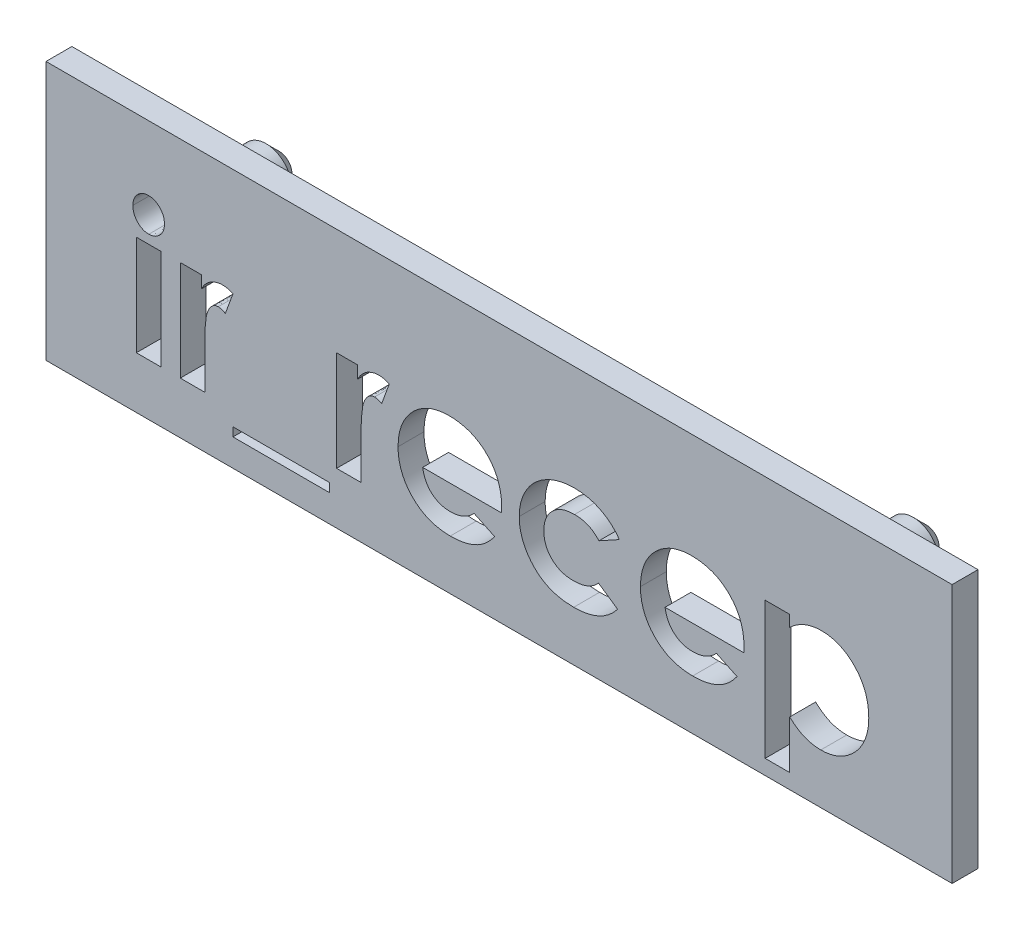
from build123d import *

# Parameters (mm, degrees)
ESQUISSE1_W             = 35
ESQUISSE1_H             = 10
BOSS_EXTRU_1_DEPTH      = 1
ESQUISSE2_R             = 1
BOSS_EXTRU_2_DEPTH      = 3
CHANFREIN1_SIZE         = 0.5
ESQUISSE3_W             = 0.949786325
ESQUISSE3_H             = 3.866987179
ESQUISSE3_W_2           = 3.731303419
ESQUISSE3_H_2           = 0.339209402
ENL_V_MAT_EXTRU_2_DEPTH = 1


with BuildPart() as part:
    # Esquisse1 → Boss.-Extru.1 (new body)
    with BuildSketch(Plane.XY):
        with Locations((17.5, -5)):
            Rectangle(ESQUISSE1_W, ESQUISSE1_H)
    extrude(amount=BOSS_EXTRU_1_DEPTH)

    # Esquisse2 → Boss.-Extru.2 (add)
    with BuildSketch(Plane(origin=(0, 0, 0), x_dir=(-1, 0, 0), z_dir=(0, 0, -1))):
        with Locations(Location((-30, -3, 0), (0, 0, 180))):  # turned: the seam where the file's is
            Circle(ESQUISSE2_R)
        with Locations(Location((-5, -3, 0), (0, 0, 180))):  # turned: the seam where the file's is
            Circle(ESQUISSE2_R)
    extrude(amount=BOSS_EXTRU_2_DEPTH)

    # Chanfrein1
    chanfrein1_edges = [part.edges().sort_by_distance(p)[0] for p in [
        (29, -3, -3),
        (4, -3, -3),
    ]]
    chamfer(chanfrein1_edges, length=CHANFREIN1_SIZE)

    # Esquisse3 → Enlèv. mat.-Extru.2 (cut)
    with BuildSketch(Plane.XY.offset(1)):
        with BuildLine():
            add(Edge.make_bspline(
                [(3.963424813, -2.504807692), (4.004360597, -2.506816157), (4.084741953, -2.51075997), (4.199899183, -2.549203379), (4.305590182, -2.609539161), (4.399023956, -2.692321292), (4.476733433, -2.791178297), (4.536106359, -2.901855287), (4.569180543, -3.024481827), (4.573774058, -3.109190958), (4.576121795, -3.152485644)],
                knots=[0, 0, 0, 0, 0.989868614, 1.943702388, 2.910836514, 3.924849579, 4.949916355, 5.946401046, 6.950409252, 8, 8, 8, 8], degree=3))
            add(Edge.make_bspline(
                [(4.576121795, -3.152485644), (4.573858056, -3.195461271), (4.569447052, -3.279201328), (4.535345136, -3.400163155), (4.478355233, -3.510786389), (4.400016358, -3.608175184), (4.307595528, -3.68962406), (4.204213959, -3.751055201), (4.090160268, -3.787360012), (4.011026189, -3.791633507), (3.970845019, -3.793803419)],
                knots=[0, 0, 0, 0, 1.05296456, 2.051751585, 3.055639087, 4.085634717, 5.099016424, 6.062201612, 7.016062274, 8, 8, 8, 8], degree=3))
            add(Edge.make_bspline(
                [(3.970845019, -3.793803419), (3.929551899, -3.791802134), (3.848471229, -3.787872533), (3.732369472, -3.749339175), (3.625268825, -3.689478577), (3.532240366, -3.605005079), (3.453640943, -3.50544562), (3.396861449, -3.392191974), (3.361344472, -3.268726916), (3.357128638, -3.182763185), (3.354967949, -3.138705262)],
                knots=[0, 0, 0, 0, 0.989065327, 1.942068821, 2.907541208, 3.917690034, 4.939857478, 5.938239964, 6.943311734, 8, 8, 8, 8], degree=3))
            add(Edge.make_bspline(
                [(3.354967949, -3.138705262), (3.357319369, -3.096459386), (3.361938395, -3.013473462), (3.395210697, -2.893573269), (3.453222204, -2.784756933), (3.530371931, -2.687709598), (3.622985043, -2.606471665), (3.728612594, -2.547968321), (3.842994812, -2.511112734), (3.92286698, -2.506931074), (3.963424813, -2.504807692)],
                knots=[0, 0, 0, 0, 1.038616768, 2.040212704, 3.031499824, 4.052181184, 5.074969369, 6.039807101, 7.004644834, 8, 8, 8, 8], degree=3))
        make_face()
        with Locations((3.965544872, -6.066506411)):
            Rectangle(ESQUISSE3_W, ESQUISSE3_H)
        with BuildLine():
            Line((5.186698718, -4.133012821), (6.000801282, -4.133012821))
            Line((6.000801282, -4.133012821), (6.000801282, -4.608966012))
            add(Edge.make_bspline(
                [(6.000801282, -4.608966012), (6.023830681, -4.566667921), (6.068842596, -4.483994547), (6.151533259, -4.373021915), (6.246531642, -4.27956386), (6.350424159, -4.201665623), (6.463525688, -4.140951595), (6.582807572, -4.097685197), (6.707249356, -4.069568033), (6.792139323, -4.066647192), (6.835044404, -4.06517094)],
                knots=[0, 0, 0, 0, 1.09866127, 2.147379032, 3.14564304, 4.131443017, 5.102343063, 6.064490016, 7.021754664, 8, 8, 8, 8], degree=3))
            add(Edge.make_bspline(
                [(6.835044404, -4.06517094), (6.866198847, -4.066629785), (6.929640418, -4.069600514), (7.026334298, -4.086869409), (7.124423302, -4.118094854), (7.188974319, -4.146209218), (7.221955128, -4.160573584)],
                knots=[0, 0, 0, 0, 0.931404136, 1.896671404, 2.925354185, 4, 4, 4, 4], degree=3))
            Line((7.221955128, -4.160573584), (6.92726696, -4.965135884))
            add(Edge.make_bspline(
                [(6.92726696, -4.965135884), (6.900926046, -4.952409228), (6.851415268, -4.928488014), (6.779534215, -4.900258516), (6.714299178, -4.883034257), (6.672941362, -4.880464246), (6.65377938, -4.879273504)],
                knots=[0, 0, 0, 0, 1.214386998, 2.282580073, 3.20428172, 4, 4, 4, 4], degree=3))
            add(Edge.make_bspline(
                [(6.65377938, -4.879273504), (6.635686743, -4.880062553), (6.600095407, -4.881614748), (6.547563592, -4.894916529), (6.498089562, -4.917855038), (6.449289164, -4.947241545), (6.405012211, -4.988090988), (6.360762607, -5.03538147), (6.321767486, -5.093767862), (6.280616325, -5.15875488), (6.245577582, -5.238298932), (6.215532939, -5.333258138), (6.188762921, -5.444731242), (6.170341494, -5.57331011), (6.152536445, -5.717750521), (6.141938443, -5.879112649), (6.134039617, -6.056886251), (6.133556657, -6.180978642), (6.133304955, -6.245651376)],
                knots=[0, 0, 0, 0, 0.544232178, 1.070598461, 1.618251235, 2.182094276, 2.777567932, 3.425210017, 4.127676488, 4.886675562, 5.738955394, 6.734782583, 7.883056018, 9.186093582, 10.642914445, 12.264202625, 14.053029461, 16, 16, 16, 16], degree=3))
            Line((6.133304955, -6.245651376), (6.136485043, -6.434336605))
            Line((6.136485043, -6.434336605), (6.136485043, -8))
            Line((6.136485043, -8), (5.186698718, -8))
            Line((5.186698718, -8), (5.186698718, -4.133012821))
        make_face()
        with Locations((9.087606838, -8.780181624)):
            Rectangle(ESQUISSE3_W_2, ESQUISSE3_H_2)
        with BuildLine():
            Line((11.224626068, -4.133012821), (12.038728632, -4.133012821))
            Line((12.038728632, -4.133012821), (12.038728632, -4.608966012))
            add(Edge.make_bspline(
                [(12.038728632, -4.608966012), (12.061758031, -4.566667921), (12.106769946, -4.483994547), (12.189460609, -4.373021915), (12.284458992, -4.27956386), (12.38835151, -4.201665623), (12.501453039, -4.140951595), (12.620734923, -4.097685197), (12.745176707, -4.069568033), (12.830066673, -4.066647192), (12.872971755, -4.06517094)],
                knots=[0, 0, 0, 0, 1.09866127, 2.147379032, 3.14564304, 4.131443017, 5.102343063, 6.064490016, 7.021754664, 8, 8, 8, 8], degree=3))
            add(Edge.make_bspline(
                [(12.872971755, -4.06517094), (12.904126198, -4.066629785), (12.967567768, -4.069600514), (13.064261649, -4.086869409), (13.162350652, -4.118094854), (13.226901669, -4.146209218), (13.259882479, -4.160573584)],
                knots=[0, 0, 0, 0, 0.931404136, 1.896671404, 2.925354185, 4, 4, 4, 4], degree=3))
            Line((13.259882479, -4.160573584), (12.965194311, -4.965135884))
            add(Edge.make_bspline(
                [(12.965194311, -4.965135884), (12.938853397, -4.952409228), (12.889342618, -4.928488014), (12.817461565, -4.900258516), (12.752226529, -4.883034257), (12.710868713, -4.880464246), (12.691706731, -4.879273504)],
                knots=[0, 0, 0, 0, 1.214386998, 2.282580073, 3.20428172, 4, 4, 4, 4], degree=3))
            add(Edge.make_bspline(
                [(12.691706731, -4.879273504), (12.673614093, -4.880062553), (12.638022758, -4.881614748), (12.585490943, -4.894916529), (12.536016912, -4.917855038), (12.487216515, -4.947241545), (12.442939562, -4.988090988), (12.398689957, -5.03538147), (12.359694836, -5.093767862), (12.318543675, -5.15875488), (12.283504933, -5.238298932), (12.25346029, -5.333258138), (12.226690272, -5.444731242), (12.208268844, -5.57331011), (12.190463795, -5.717750521), (12.179865793, -5.879112649), (12.171966968, -6.056886251), (12.171484007, -6.180978642), (12.171232305, -6.245651376)],
                knots=[0, 0, 0, 0, 0.544232178, 1.070598461, 1.618251235, 2.182094276, 2.777567932, 3.425210017, 4.127676488, 4.886675562, 5.738955394, 6.734782583, 7.883056018, 9.186093582, 10.642914445, 12.264202625, 14.053029461, 16, 16, 16, 16], degree=3))
            Line((12.171232305, -6.245651376), (12.174412393, -6.434336605))
            Line((12.174412393, -6.434336605), (12.174412393, -8))
            Line((12.174412393, -8), (11.224626068, -8))
            Line((11.224626068, -8), (11.224626068, -4.133012821))
        make_face()
        with BuildLine():
            Line((17.598582732, -6.303952991), (14.548878205, -6.303952991))
            add(Edge.make_bspline(
                [(14.548878205, -6.303952991), (14.555096306, -6.339388828), (14.567315366, -6.409023042), (14.593849488, -6.510172781), (14.627711008, -6.605494587), (14.668291907, -6.695115884), (14.714907991, -6.779510462), (14.769281791, -6.858282479), (14.830723625, -6.931362358), (14.898878253, -6.998432487), (14.97260966, -7.058528775), (15.051560278, -7.111176923), (15.135811576, -7.154345184), (15.224397647, -7.190731548), (15.317980432, -7.219553234), (15.416697662, -7.239431004), (15.520287651, -7.251172875), (15.590856316, -7.252871202), (15.626928085, -7.253739316)],
                knots=[0, 0, 0, 0, 1.091296461, 2.144483647, 3.168565212, 4.157007626, 5.126487748, 6.090021542, 7.05641414, 8.019231907, 8.98705074, 9.938580405, 10.892824166, 11.854447369, 12.841318655, 13.858982407, 14.905600794, 16, 16, 16, 16], degree=3))
            add(Edge.make_bspline(
                [(15.626928085, -7.253739316), (15.670469158, -7.25258979), (15.756214355, -7.250326034), (15.881831706, -7.23024988), (16.003321983, -7.199925733), (16.119535459, -7.15483118), (16.231818286, -7.098696389), (16.338321943, -7.028759346), (16.440889925, -6.947063841), (16.503468481, -6.884092976), (16.535373264, -6.851988181)],
                knots=[0, 0, 0, 0, 1.021034703, 2.010718019, 2.977989445, 3.954245119, 4.929443971, 5.918328161, 6.938689359, 8, 8, 8, 8], degree=3))
            Line((16.535373264, -6.851988181), (17.330395299, -7.23041867))
            add(Edge.make_bspline(
                [(17.330395299, -7.23041867), (17.305364494, -7.2650074), (17.255766875, -7.333543698), (17.174800426, -7.42999197), (17.090306781, -7.51998212), (17.002222925, -7.602922269), (16.910437145, -7.678576072), (16.815204767, -7.747865128), (16.715134009, -7.808929053), (16.612225767, -7.864722083), (16.504352738, -7.91255319), (16.391813455, -7.953341869), (16.275084583, -7.990214488), (16.15269209, -8.018309404), (16.025655137, -8.04054911), (15.893669827, -8.056342248), (15.756753554, -8.066096912), (15.663692362, -8.067253315), (15.616327791, -8.06784188)],
                knots=[0, 0, 0, 0, 1.028154879, 2.037251081, 3.030720504, 4.000128189, 4.949298328, 5.894184978, 6.834267904, 7.770992897, 8.712077017, 9.673380525, 10.653304757, 11.658697181, 12.695551717, 13.758623199, 14.859225354, 16, 16, 16, 16], degree=3))
            add(Edge.make_bspline(
                [(15.616327791, -8.06784188), (15.543458177, -8.066356288), (15.400747238, -8.063446841), (15.192006692, -8.036443012), (14.993761069, -7.991667753), (14.805450594, -7.930802664), (14.627889269, -7.85044168), (14.460989219, -7.752153529), (14.303082873, -7.637822594), (14.158995153, -7.505049371), (14.027726989, -7.360533612), (13.912429196, -7.205333555), (13.815949644, -7.040533524), (13.736718695, -6.867224201), (13.67513765, -6.684961981), (13.630741288, -6.49366733), (13.603525786, -6.293431612), (13.600586377, -6.157048736), (13.59909188, -6.087706998)],
                knots=[0, 0, 0, 0, 1.103565453, 2.161269334, 3.182010356, 4.179077853, 5.15417608, 6.128274628, 7.109042802, 8.101804412, 9.090965879, 10.063106201, 11.02526161, 11.978650795, 12.945248442, 13.93468508, 14.949922959, 16, 16, 16, 16], degree=3))
            add(Edge.make_bspline(
                [(13.59909188, -6.087706998), (13.600601086, -6.016603197), (13.60357038, -5.876709662), (13.630506963, -5.67185041), (13.675260391, -5.476386975), (13.737021574, -5.290050184), (13.815050579, -5.112257255), (13.912757668, -4.944563662), (14.027669773, -4.786385588), (14.158465046, -4.638463007), (14.303163167, -4.504946716), (14.45691859, -4.385957019), (14.621458917, -4.286806905), (14.794923053, -4.206693674), (14.976201461, -4.141603697), (15.167389465, -4.098291753), (15.367032415, -4.069210375), (15.50350394, -4.066532162), (15.572866587, -4.06517094)],
                knots=[0, 0, 0, 0, 1.079208495, 2.12329425, 3.130605359, 4.119693003, 5.099659317, 6.073216462, 7.060498243, 8.06384408, 9.066070512, 10.045757761, 11.010926815, 11.975797609, 12.942977511, 13.929384301, 14.947594487, 16, 16, 16, 16], degree=3))
            add(Edge.make_bspline(
                [(15.572866587, -4.06517094), (15.646085295, -4.06667958), (15.789842684, -4.06964164), (16.000037044, -4.096426204), (16.199598994, -4.141474498), (16.389378779, -4.201813297), (16.566952834, -4.284204284), (16.736222999, -4.380073719), (16.893129216, -4.496876004), (17.039343937, -4.628999478), (17.171332606, -4.775585892), (17.286705327, -4.934823635), (17.384873313, -5.105158639), (17.46443944, -5.287281648), (17.525957253, -5.480645912), (17.570394711, -5.68500031), (17.597402624, -5.901122106), (17.600287337, -6.049113087), (17.601762821, -6.124808026)],
                knots=[0, 0, 0, 0, 1.080001299, 2.120471247, 3.119684163, 4.095710327, 5.052285597, 6.002875087, 6.961153713, 7.931888285, 8.906493152, 9.865905668, 10.82813294, 11.801621613, 12.7925306, 13.817193356, 14.883530496, 16, 16, 16, 16], degree=3))
            Line((17.601762821, -6.124808026), (17.598582732, -6.303952991))
        make_face()
        with BuildLine():
            Line((22.147168803, -4.921674679), (21.360627003, -5.354166667))
            add(Edge.make_bspline(
                [(21.360627003, -5.354166667), (21.324574794, -5.318063555), (21.255273383, -5.248664299), (21.144143002, -5.16081585), (21.034998375, -5.088079778), (20.92333992, -5.034404293), (20.808169544, -4.993981508), (20.685333191, -4.96720861), (20.553397145, -4.949579608), (20.462136832, -4.947953728), (20.415080796, -4.947115385)],
                knots=[0, 0, 0, 0, 1.150764855, 2.212059359, 3.192108068, 4.105322427, 5.000809612, 5.941206042, 6.938435785, 8, 8, 8, 8], degree=3))
            add(Edge.make_bspline(
                [(20.415080796, -4.947115385), (20.371927163, -4.948157704), (20.287479123, -4.950197436), (20.164087135, -4.965432834), (20.046815695, -4.989361835), (19.935875311, -5.024370047), (19.831463579, -5.0706178), (19.73271706, -5.12534506), (19.640595309, -5.190689399), (19.556400493, -5.265721963), (19.480399873, -5.348331153), (19.412603443, -5.436437405), (19.357062156, -5.531347754), (19.309043269, -5.630831462), (19.273739197, -5.736757056), (19.247909879, -5.848163371), (19.233187409, -5.965055344), (19.231054383, -6.044912531), (19.229967949, -6.085586939)],
                knots=[0, 0, 0, 0, 1.121765476, 2.195200973, 3.227634963, 4.230038321, 5.213228299, 6.192116585, 7.160777141, 8.14345191, 9.118668839, 10.075979138, 11.027630062, 11.972829041, 12.943187208, 13.923755399, 14.94248691, 16, 16, 16, 16], degree=3))
            add(Edge.make_bspline(
                [(19.229967949, -6.085586939), (19.23111586, -6.125199879), (19.233357238, -6.202546952), (19.247127508, -6.316188233), (19.271033216, -6.424369883), (19.306876696, -6.526519978), (19.349839113, -6.623580196), (19.403792045, -6.714778598), (19.46723772, -6.800513425), (19.540510155, -6.880039516), (19.621677418, -6.951563477), (19.709182093, -7.01472654), (19.8027631, -7.068277132), (19.903510566, -7.110302311), (20.009781903, -7.144544041), (20.122286797, -7.168925493), (20.240905523, -7.182458885), (20.321764905, -7.184733534), (20.363139356, -7.185897436)],
                knots=[0, 0, 0, 0, 1.070556293, 2.090336998, 3.088792742, 4.058148387, 5.011235098, 5.952916408, 6.915475435, 7.888633318, 8.869583867, 9.83422472, 10.800707077, 11.776204622, 12.778807041, 13.814557445, 14.881744048, 16, 16, 16, 16], degree=3))
            add(Edge.make_bspline(
                [(20.363139356, -7.185897436), (20.414081222, -7.184731737), (20.513512341, -7.182456462), (20.658056332, -7.163158313), (20.79407025, -7.131245961), (20.921568518, -7.08707673), (21.040372765, -7.029324638), (21.150177731, -6.958784767), (21.252112208, -6.875977477), (21.31155478, -6.811419049), (21.341546474, -6.778846154)],
                knots=[0, 0, 0, 0, 1.116373375, 2.178998604, 3.189797796, 4.174590301, 5.13072713, 6.078291395, 7.030403691, 8, 8, 8, 8], degree=3))
            Line((21.341546474, -6.778846154), (22.079326923, -7.285540198))
            add(Edge.make_bspline(
                [(22.079326923, -7.285540198), (22.028187526, -7.348064577), (21.927267815, -7.471451686), (21.751190903, -7.630493165), (21.561678964, -7.767145135), (21.354920503, -7.876219005), (21.133926605, -7.962973325), (20.896970417, -8.024300017), (20.644452733, -8.060400427), (20.471028031, -8.065321747), (20.382219885, -8.06784188)],
                knots=[0, 0, 0, 0, 0.997876357, 1.969233105, 2.924898516, 3.881013542, 4.852507933, 5.855329832, 6.901747111, 8, 8, 8, 8], degree=3))
            add(Edge.make_bspline(
                [(20.382219885, -8.06784188), (20.302287046, -8.06599407), (20.146169399, -8.062385093), (19.918631806, -8.034747141), (19.704620884, -7.988194771), (19.503696381, -7.923543097), (19.316041481, -7.839794971), (19.142264766, -7.735916003), (18.981194114, -7.614795726), (18.835735888, -7.475861975), (18.705953774, -7.324631087), (18.592653521, -7.165360916), (18.49466628, -7.000905122), (18.417795385, -6.828526399), (18.354970677, -6.650911564), (18.312540841, -6.465937483), (18.284555751, -6.275127813), (18.281651402, -6.145756539), (18.280181624, -6.080286792)],
                knots=[0, 0, 0, 0, 1.183377041, 2.311265848, 3.387807024, 4.421911742, 5.431260577, 6.423665966, 7.413571885, 8.409103097, 9.395976332, 10.359992013, 11.300391101, 12.225292883, 13.150239058, 14.085544813, 15.031169026, 16, 16, 16, 16], degree=3))
            add(Edge.make_bspline(
                [(18.280181624, -6.080286792), (18.280968995, -6.034673464), (18.282528534, -5.944327486), (18.295842067, -5.810153634), (18.316553451, -5.678256658), (18.347680216, -5.549562407), (18.385960642, -5.423446502), (18.432495683, -5.299934295), (18.489120854, -5.17966313), (18.552286403, -5.061609908), (18.624277538, -4.94889106), (18.702818373, -4.841556334), (18.787798251, -4.740263106), (18.880215471, -4.645955402), (18.97942564, -4.557958412), (19.083986501, -4.474486841), (19.197281592, -4.399845508), (19.315372338, -4.329668868), (19.439275969, -4.267198143), (19.567568382, -4.213277671), (19.699258164, -4.167464453), (19.834660967, -4.130629702), (19.973195617, -4.100271113), (20.116094826, -4.081004305), (20.262176344, -4.067462079), (20.360987139, -4.065939258), (20.410840678, -4.06517094)],
                knots=[0, 0, 0, 0, 1.00272354, 1.986087015, 2.96193297, 3.936200312, 4.894695956, 5.858592327, 6.835334787, 7.815655071, 8.800643866, 9.773423113, 10.738352213, 11.705312252, 12.673769326, 13.65298065, 14.64420052, 15.654211674, 16.672258995, 17.692438602, 18.712115155, 19.735602823, 20.776372304, 21.827874031, 22.90408564, 24, 24, 24, 24], degree=3))
            add(Edge.make_bspline(
                [(20.410840678, -4.06517094), (20.457148221, -4.065694486), (20.548476486, -4.06672703), (20.68334769, -4.07752371), (20.814539881, -4.095862345), (20.942276324, -4.120123587), (21.066944954, -4.150187491), (21.186874879, -4.190261668), (21.303705745, -4.235744349), (21.454185134, -4.304418449), (21.631572791, -4.406925659), (21.826296915, -4.553943595), (21.999917043, -4.725933137), (22.097823997, -4.856080703), (22.147168803, -4.921674679)],
                knots=[0, 0, 0, 0, 0.826738014, 1.630502179, 2.413926014, 3.191023582, 3.95155221, 4.701751672, 5.446919844, 6.189438973, 7.653650558, 9.094719814, 10.535747635, 12, 12, 12, 12], degree=3))
        make_face()
        with BuildLine():
            Line((26.96076222, -6.303952991), (23.911057692, -6.303952991))
            add(Edge.make_bspline(
                [(23.911057692, -6.303952991), (23.917275794, -6.339388828), (23.929494853, -6.409023042), (23.956028975, -6.510172781), (23.989890495, -6.605494587), (24.030471394, -6.695115884), (24.077087478, -6.779510462), (24.131461278, -6.858282479), (24.192903113, -6.931362358), (24.26105774, -6.998432487), (24.334789148, -7.058528775), (24.413739765, -7.111176923), (24.497991063, -7.154345184), (24.586577134, -7.190731548), (24.680159919, -7.219553234), (24.778877149, -7.239431004), (24.882467138, -7.251172875), (24.953035803, -7.252871202), (24.989107572, -7.253739316)],
                knots=[0, 0, 0, 0, 1.091296461, 2.144483647, 3.168565212, 4.157007626, 5.126487748, 6.090021542, 7.05641414, 8.019231907, 8.98705074, 9.938580405, 10.892824166, 11.854447369, 12.841318655, 13.858982407, 14.905600794, 16, 16, 16, 16], degree=3))
            add(Edge.make_bspline(
                [(24.989107572, -7.253739316), (25.032648646, -7.25258979), (25.118393842, -7.250326034), (25.244011193, -7.23024988), (25.36550147, -7.199925733), (25.481714946, -7.15483118), (25.593997773, -7.098696389), (25.70050143, -7.028759346), (25.803069412, -6.947063841), (25.865647968, -6.884092976), (25.897552751, -6.851988181)],
                knots=[0, 0, 0, 0, 1.021034703, 2.010718019, 2.977989445, 3.954245119, 4.929443971, 5.918328161, 6.938689359, 8, 8, 8, 8], degree=3))
            Line((25.897552751, -6.851988181), (26.692574786, -7.23041867))
            add(Edge.make_bspline(
                [(26.692574786, -7.23041867), (26.667543982, -7.2650074), (26.617946362, -7.333543698), (26.536979914, -7.42999197), (26.452486268, -7.51998212), (26.364402412, -7.602922269), (26.272616632, -7.678576072), (26.177384254, -7.747865128), (26.077313496, -7.808929053), (25.974405254, -7.864722083), (25.866532226, -7.91255319), (25.753992942, -7.953341869), (25.63726407, -7.990214488), (25.514871578, -8.018309404), (25.387834625, -8.04054911), (25.255849314, -8.056342248), (25.118933042, -8.066096912), (25.025871849, -8.067253315), (24.978507278, -8.06784188)],
                knots=[0, 0, 0, 0, 1.028154879, 2.037251081, 3.030720504, 4.000128189, 4.949298328, 5.894184978, 6.834267904, 7.770992897, 8.712077017, 9.673380525, 10.653304757, 11.658697181, 12.695551717, 13.758623199, 14.859225354, 16, 16, 16, 16], degree=3))
            add(Edge.make_bspline(
                [(24.978507278, -8.06784188), (24.905637664, -8.066356288), (24.762926726, -8.063446841), (24.554186179, -8.036443012), (24.355940557, -7.991667753), (24.167630081, -7.930802664), (23.990068756, -7.85044168), (23.823168706, -7.752153529), (23.665262361, -7.637822594), (23.521174641, -7.505049371), (23.389906476, -7.360533612), (23.274608683, -7.205333555), (23.178129131, -7.040533524), (23.098898183, -6.867224201), (23.037317137, -6.684961981), (22.992920775, -6.49366733), (22.965705274, -6.293431612), (22.962765864, -6.157048736), (22.961271368, -6.087706998)],
                knots=[0, 0, 0, 0, 1.103565453, 2.161269334, 3.182010356, 4.179077853, 5.15417608, 6.128274628, 7.109042802, 8.101804412, 9.090965879, 10.063106201, 11.02526161, 11.978650795, 12.945248442, 13.93468508, 14.949922959, 16, 16, 16, 16], degree=3))
            add(Edge.make_bspline(
                [(22.961271368, -6.087706998), (22.962780573, -6.016603197), (22.965749868, -5.876709662), (22.99268645, -5.67185041), (23.037439878, -5.476386975), (23.099201061, -5.290050184), (23.177230066, -5.112257255), (23.274937155, -4.944563662), (23.38984926, -4.786385588), (23.520644534, -4.638463007), (23.665342654, -4.504946716), (23.819098077, -4.385957019), (23.983638404, -4.286806905), (24.15710254, -4.206693674), (24.338380948, -4.141603697), (24.529568952, -4.098291753), (24.729211902, -4.069210375), (24.865683427, -4.066532162), (24.935046074, -4.06517094)],
                knots=[0, 0, 0, 0, 1.079208495, 2.12329425, 3.130605359, 4.119693003, 5.099659317, 6.073216462, 7.060498243, 8.06384408, 9.066070512, 10.045757761, 11.010926815, 11.975797609, 12.942977511, 13.929384301, 14.947594487, 16, 16, 16, 16], degree=3))
            add(Edge.make_bspline(
                [(24.935046074, -4.06517094), (25.008264783, -4.06667958), (25.152022171, -4.06964164), (25.362216531, -4.096426204), (25.561778481, -4.141474498), (25.751558266, -4.201813297), (25.929132321, -4.284204284), (26.098402486, -4.380073719), (26.255308703, -4.496876004), (26.401523425, -4.628999478), (26.533512093, -4.775585892), (26.648884814, -4.934823635), (26.7470528, -5.105158639), (26.826618927, -5.287281648), (26.88813674, -5.480645912), (26.932574199, -5.68500031), (26.959582111, -5.901122106), (26.962466824, -6.049113087), (26.963942308, -6.124808026)],
                knots=[0, 0, 0, 0, 1.080001299, 2.120471247, 3.119684163, 4.095710327, 5.052285597, 6.002875087, 6.961153713, 7.931888285, 8.906493152, 9.865905668, 10.82813294, 11.801621613, 12.7925306, 13.817193356, 14.883530496, 16, 16, 16, 16], degree=3))
            Line((26.963942308, -6.124808026), (26.96076222, -6.303952991))
        make_face()
        with BuildLine():
            Line((28.727831197, -4.133012821), (28.727831197, -4.568684896))
            add(Edge.make_bspline(
                [(28.727831197, -4.568684896), (28.771925602, -4.528171753), (28.858522465, -4.448608122), (29.000304956, -4.346742923), (29.146007868, -4.259256524), (29.298308338, -4.188889417), (29.455116244, -4.133445707), (29.617836677, -4.09448843), (29.785273308, -4.068795061), (29.899068263, -4.066385185), (29.956405248, -4.06517094)],
                knots=[0, 0, 0, 0, 1.054376801, 2.070687235, 3.070225973, 4.045259405, 5.022040922, 5.996139433, 6.99033025, 8, 8, 8, 8], degree=3))
            add(Edge.make_bspline(
                [(29.956405248, -4.06517094), (30.0186912, -4.066662846), (30.141374313, -4.069601416), (30.321879172, -4.097037187), (30.494860487, -4.141385223), (30.66097788, -4.203307169), (30.819346297, -4.283702473), (30.97174512, -4.379960671), (31.115546052, -4.496053903), (31.250818999, -4.627548954), (31.375949846, -4.771677298), (31.484790637, -4.928375398), (31.575450793, -5.095580805), (31.652289729, -5.271316802), (31.708369871, -5.458497913), (31.751591765, -5.654613228), (31.77567743, -5.861321926), (31.779014582, -6.002139788), (31.780715812, -6.073926616)],
                knots=[0, 0, 0, 0, 0.985987466, 1.942075377, 2.884088208, 3.810275091, 4.743821533, 5.692411115, 6.659945104, 7.665215984, 8.677116751, 9.678438675, 10.680260931, 11.685531812, 12.710472044, 13.769734641, 14.863044265, 16, 16, 16, 16], degree=3))
            add(Edge.make_bspline(
                [(31.780715812, -6.073926616), (31.779105711, -6.14325599), (31.775931848, -6.279919471), (31.750289034, -6.480552708), (31.706826611, -6.672214326), (31.645857639, -6.854973348), (31.56834965, -7.029407327), (31.4737458, -7.195396066), (31.361494244, -7.352359771), (31.233161749, -7.498183983), (31.092939848, -7.630238647), (30.946838678, -7.748717936), (30.791948384, -7.845802422), (30.632140878, -7.927797708), (30.464898585, -7.990497917), (30.291363844, -8.03442646), (30.111811491, -8.063795417), (29.989737761, -8.066479625), (29.927784455, -8.06784188)],
                knots=[0, 0, 0, 0, 1.098553145, 2.165490463, 3.199345634, 4.208780719, 5.21409072, 6.219899742, 7.23156933, 8.267303578, 9.293302409, 10.281606823, 11.243293419, 12.184993323, 13.124258899, 14.066907486, 15.018941492, 16, 16, 16, 16], degree=3))
            add(Edge.make_bspline(
                [(29.927784455, -8.06784188), (29.87257689, -8.066502987), (29.763821308, -8.063865449), (29.603898756, -8.040348446), (29.449411755, -8.005222037), (29.300155949, -7.952352875), (29.154453437, -7.882195943), (29.009822724, -7.794828168), (28.865929368, -7.688093559), (28.774851563, -7.605769171), (28.727831197, -7.563267895)],
                knots=[0, 0, 0, 0, 0.990856396, 1.951927477, 2.896945079, 3.83213376, 4.788585491, 5.796263726, 6.862286081, 8, 8, 8, 8], degree=3))
            Line((28.727831197, -7.563267895), (28.727831197, -9.424679487))
            Line((28.727831197, -9.424679487), (27.778044872, -9.424679487))
            Line((27.778044872, -9.424679487), (27.778044872, -4.133012821))
            Line((27.778044872, -4.133012821), (28.727831197, -4.133012821))
        make_face()
    extrude(amount=-ENL_V_MAT_EXTRU_2_DEPTH, mode=Mode.SUBTRACT)


solid = part.part
